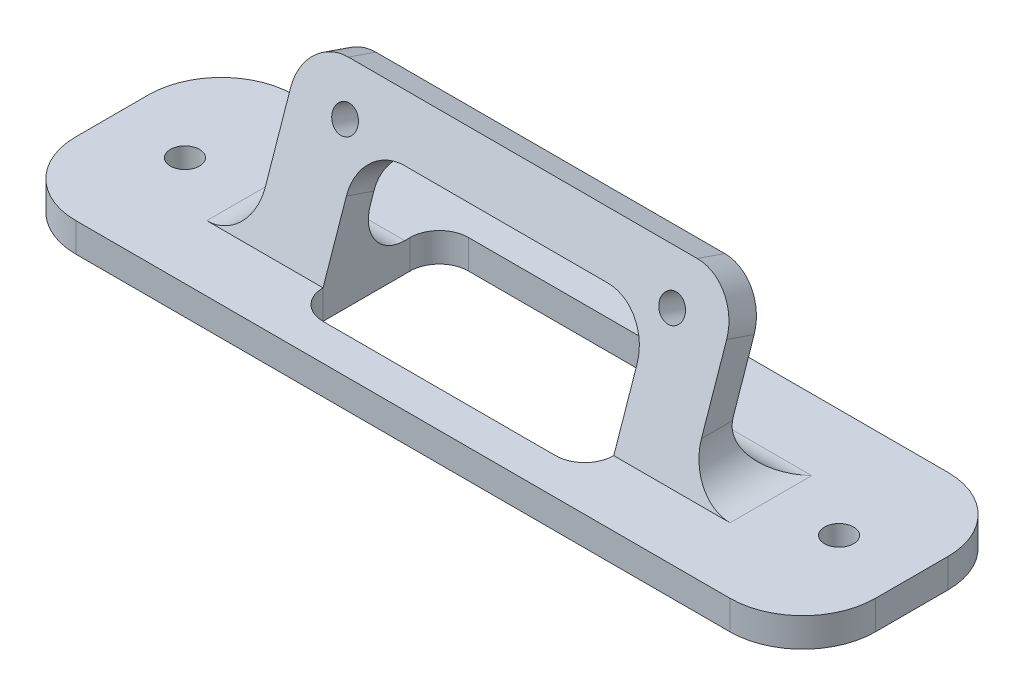
from build123d import *

# Parameters (mm, degrees)
ESQUISSE1_R                  = 2
BOSS_EXTRU_1_DEPTH           = 4
BOSS_EXTRU_2_DEPTH           = 30
BOSS_EXTRU_2_DEPTH_BACK      = 30
ENL_V_MAT_EXTRU_1_REACH      = 23.158
ESQUISSE3_R                  = 1.75
CONG_1_R                     = 6
CONG_2_R                     = 5
ESQUISSE4_W                  = 40
ESQUISSE4_H                  = 20
ENL_V_MAT_EXTRU_2_DEPTH      = 15
ENL_V_MAT_EXTRU_2_DEPTH_BACK = 22
ESQUISSE5_W                  = 40
ESQUISSE5_H                  = 7.135689783
BOSS_EXTRU_3_DEPTH           = 4
CONG_4_R                     = 6
CONG_5_R                     = 4


with BuildPart() as part:
    # Esquisse1 → Boss.-Extru.1 (new body)
    with BuildSketch(Plane(origin=(0, 0, 0), x_dir=(1, 0, 0), z_dir=(0, 1, 0))):
        with BuildLine():
            Line((-45, 15), (45, 15))
            ThreePointArc((45, 15), (52.071067812, 12.071067812), (55, 5))
            Line((55, 5), (55, -5))
            ThreePointArc((55, -5), (52.071067812, -12.071067812), (45, -15))
            Line((45, -15), (-45, -15))
            ThreePointArc((-45, -15), (-52.071067812, -12.071067812), (-55, -5))
            Line((-55, -5), (-55, 5))
            ThreePointArc((-55, 5), (-52.071067812, 12.071067812), (-45, 15))
        make_face()
        with Locations((-45, 0)):
            Circle(ESQUISSE1_R, mode=Mode.SUBTRACT)
        with Locations((45, 0)):
            Circle(ESQUISSE1_R, mode=Mode.SUBTRACT)
    extrude(amount=BOSS_EXTRU_1_DEPTH)

    # Esquisse2 → Boss.-Extru.2 (add, two sides)
    with BuildSketch(Plane(origin=(0, 0, 0), x_dir=(0, 0, -1), z_dir=(1, 0, 0))) as boss_extru_2_sk:
        Polygon((-6, 4), (1.488067553, 25.746927239), (5.270141855, 24.444654621), (-1.769517275, 4), align=None)
    extrude(amount=BOSS_EXTRU_2_DEPTH)
    extrude(boss_extru_2_sk.sketch, amount=-BOSS_EXTRU_2_DEPTH_BACK)

    # Esquisse3 → Enlèv. mat.-Extru.1 (cut, up to next)
    with BuildSketch(Plane(origin=(0, 2.270962919, 6.595355211), x_dir=(1, 0, 0), z_dir=(0, 0.325568154, 0.945518576)), mode=Mode.PRIVATE) as enl_v_mat_extru_1_sk1:
        with Locations((22.5, 18.828665376)):
            Circle(ESQUISSE3_R)
    enl_v_mat_extru_1_tool1 = extrude(enl_v_mat_extru_1_sk1.sketch, amount=-ENL_V_MAT_EXTRU_1_REACH, mode=Mode.PRIVATE) & part.part
    add(enl_v_mat_extru_1_tool1.solids().sort_by_distance((22.5, 20.073816, 0.465341))[0], mode=Mode.SUBTRACT)
    # Esquisse3 → Enlèv. mat.-Extru.1 (cut, up to next)
    with BuildSketch(Plane(origin=(0, 2.270962919, 6.595355211), x_dir=(1, 0, 0), z_dir=(0, 0.325568154, 0.945518576)), mode=Mode.PRIVATE) as enl_v_mat_extru_1_sk2:
        with Locations((-22.5, 18.828665376)):
            Circle(ESQUISSE3_R)
    enl_v_mat_extru_1_tool2 = extrude(enl_v_mat_extru_1_sk2.sketch, amount=-ENL_V_MAT_EXTRU_1_REACH, mode=Mode.PRIVATE) & part.part
    add(enl_v_mat_extru_1_tool2.solids().sort_by_distance((-22.5, 20.073816, 0.465341))[0], mode=Mode.SUBTRACT)

    # Congé1
    cong_1_edges = [part.edges().sort_by_distance(p)[0] for p in [
        (-30, 4, 3.884758638),
        (-30, 25.09579093, -3.379104704),
        (30, 4, 3.884758638),
        (30, 25.09579093, -3.379104704),
    ]]
    fillet(cong_1_edges, radius=CONG_1_R)

    # Congé2
    cong_2_edges = [part.edges().sort_by_distance(p)[0] for p in [
        (0, 4, 1.769517275),
    ]]
    fillet(cong_2_edges, radius=CONG_2_R)

    # Esquisse4 → Enlèv. mat.-Extru.2 (cut, two sides)
    with BuildSketch(Plane(origin=(0, 4, 0), x_dir=(1, 0, 0), z_dir=(0, 1, 0))) as enl_v_mat_extru_2_sk:
        Rectangle(ESQUISSE4_W, ESQUISSE4_H)
    extrude(amount=ENL_V_MAT_EXTRU_2_DEPTH, mode=Mode.SUBTRACT)
    extrude(enl_v_mat_extru_2_sk.sketch, amount=-ENL_V_MAT_EXTRU_2_DEPTH_BACK, mode=Mode.SUBTRACT)

    # Esquisse5 → Boss.-Extru.3 (add)
    with BuildSketch(Plane(origin=(0, 2.270962919, 6.595355211), x_dir=(1, 0, 0), z_dir=(0, 0.325568154, 0.945518576))):
        with Locations((0, 21.260820485)):
            Rectangle(ESQUISSE5_W, ESQUISSE5_H)
    extrude(amount=-BOSS_EXTRU_3_DEPTH)

    # Congé4
    cong_4_edges = [part.edges().sort_by_distance(p)[0] for p in [
        (-20, 18.348863691, -1.055951351),
        (20, 18.348863691, -1.055951351),
    ]]
    fillet(cong_4_edges, radius=CONG_4_R)

    # Congé5
    cong_5_edges = [part.edges().sort_by_distance(p)[0] for p in [
        (-20, 2, 10),
        (20, 2, -10),
        (-20, 2, -10),
        (20, 2, 10),
    ]]
    fillet(cong_5_edges, radius=CONG_5_R)


solid = part.part
